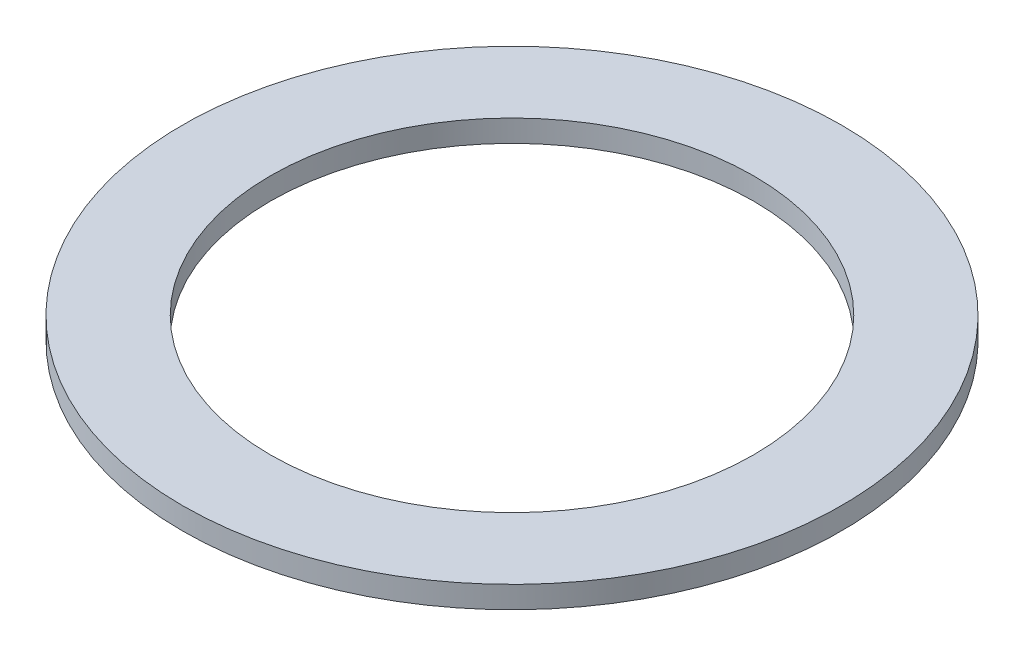
from build123d import *

# Parameters (mm, degrees)
SKETCH3_R           = 38.1
SKETCH3_R_2         = 27.94
BOSS_EXTRUDE4_DEPTH = 2.54


with BuildPart() as part:
    # Sketch3 → Boss-Extrude4 (new body)
    with BuildSketch(Plane(origin=(0, 0, 0), x_dir=(1, 0, 0), z_dir=(0, 1, 0))):
        with Locations(Location((-169.493181638, 146.319449112, 0), (0, 0, 270))):  # turned: the seam where the file's is
            Circle(SKETCH3_R)
        with Locations(Location((-169.493181638, 146.319449112, 0), (0, 0, 270))):  # turned: the seam where the file's is
            Circle(SKETCH3_R_2, mode=Mode.SUBTRACT)
    extrude(amount=BOSS_EXTRUDE4_DEPTH)


solid = part.part
